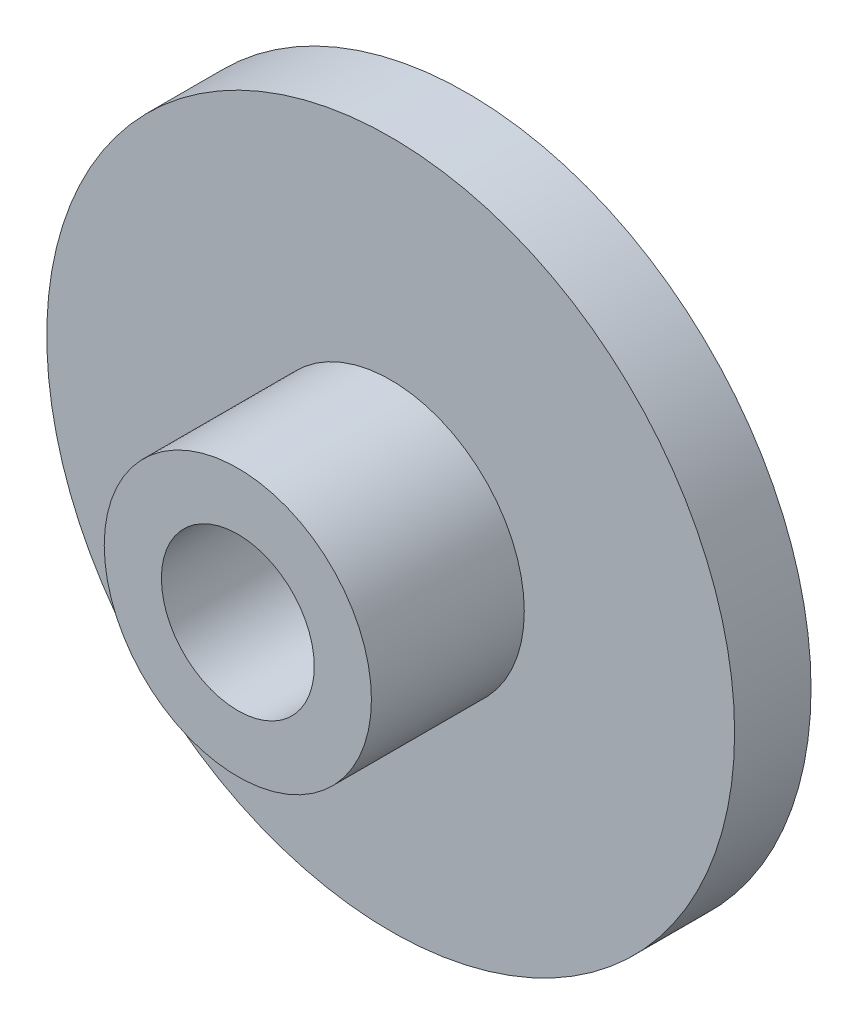
from build123d import *

# Parameters (mm, degrees)
SKETCH1_R           = 14.2875
BOSS_EXTRUDE1_DEPTH = 3.175
SKETCH2_R           = 5.5499
BOSS_EXTRUDE2_DEPTH = 6.35
SKETCH3_R           = 3.175
CUT_EXTRUDE1_DEPTH  = 11.43


with BuildPart() as part:
    # Sketch1 → Boss-Extrude1 (new body)
    with BuildSketch(Plane.XY):
        Circle(SKETCH1_R)
    extrude(amount=BOSS_EXTRUDE1_DEPTH)

    # Sketch2 → Boss-Extrude2 (add)
    with BuildSketch(Plane.XY.offset(3.175)):
        Circle(SKETCH2_R)
    extrude(amount=BOSS_EXTRUDE2_DEPTH)

    # Sketch3 → Cut-Extrude1 (cut)
    with BuildSketch(Plane(origin=(0, 0, 0), x_dir=(-1, 0, 0), z_dir=(0, 0, -1))):
        Circle(SKETCH3_R)
    extrude(amount=-CUT_EXTRUDE1_DEPTH, mode=Mode.SUBTRACT)


solid = part.part
